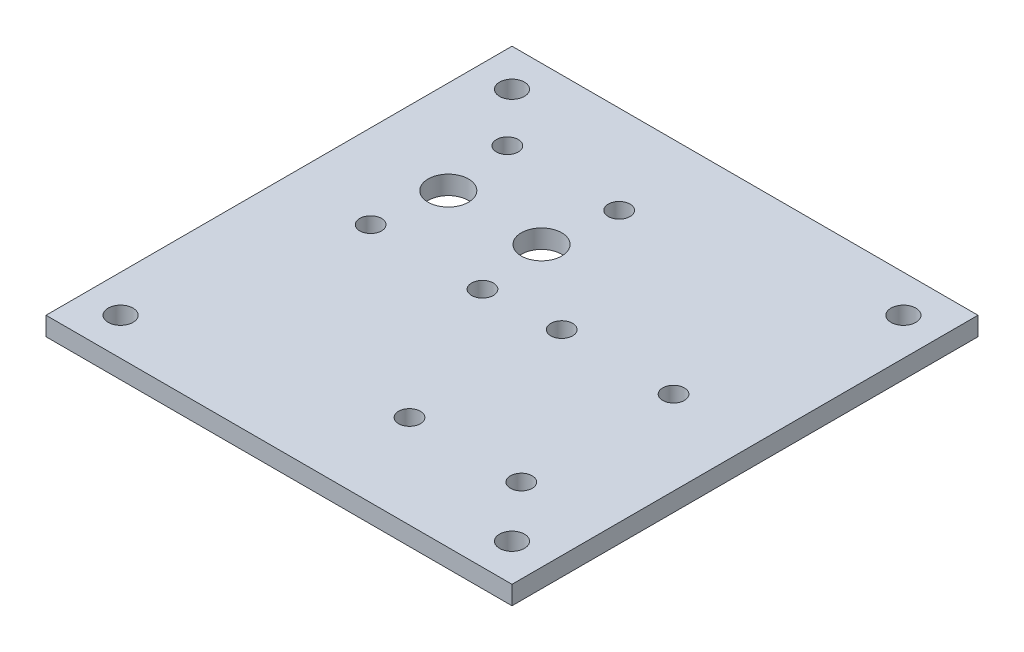
from build123d import *

# Parameters (mm, degrees)
SKETCH1_W           = 75
SKETCH1_H           = 75
SKETCH1_R           = 2
SKETCH1_R_2         = 3.25
SKETCH1_R_3         = 1.75
BOSS_EXTRUDE1_DEPTH = 3


with BuildPart() as part:
    # Sketch1 → Boss-Extrude1 (new body)
    with BuildSketch(Plane(origin=(0, 0, 0), x_dir=(1, 0, 0), z_dir=(0, 1, 0))):
        Rectangle(SKETCH1_W, SKETCH1_H)
        with Locations((31.5, 31.5)):
            Circle(SKETCH1_R, mode=Mode.SUBTRACT)
        with Locations((31.5, -31.5)):
            Circle(SKETCH1_R, mode=Mode.SUBTRACT)
        with Locations((-31.5, -31.5)):
            Circle(SKETCH1_R, mode=Mode.SUBTRACT)
        with Locations((-31.5, 31.5)):
            Circle(SKETCH1_R, mode=Mode.SUBTRACT)
        with Locations((-22.5, 12.25)):
            Circle(SKETCH1_R_2, mode=Mode.SUBTRACT)
        with Locations((-7.5, 12.25)):
            Circle(SKETCH1_R_2, mode=Mode.SUBTRACT)
        with Locations((-24, 23.25)):
            Circle(SKETCH1_R_3, mode=Mode.SUBTRACT)
        with Locations((-6, 23.25)):
            Circle(SKETCH1_R_3, mode=Mode.SUBTRACT)
        with Locations((-24, 1.25)):
            Circle(SKETCH1_R_3, mode=Mode.SUBTRACT)
        with Locations((-6, 1.25)):
            Circle(SKETCH1_R_3, mode=Mode.SUBTRACT)
        with Locations((6, -22.5)):
            Circle(SKETCH1_R_3, mode=Mode.SUBTRACT)
        with Locations((24, -22.5)):
            Circle(SKETCH1_R_3, mode=Mode.SUBTRACT)
        with Locations((24, 2)):
            Circle(SKETCH1_R_3, mode=Mode.SUBTRACT)
        with Locations((6, 2)):
            Circle(SKETCH1_R_3, mode=Mode.SUBTRACT)
    extrude(amount=BOSS_EXTRUDE1_DEPTH)


solid = part.part
